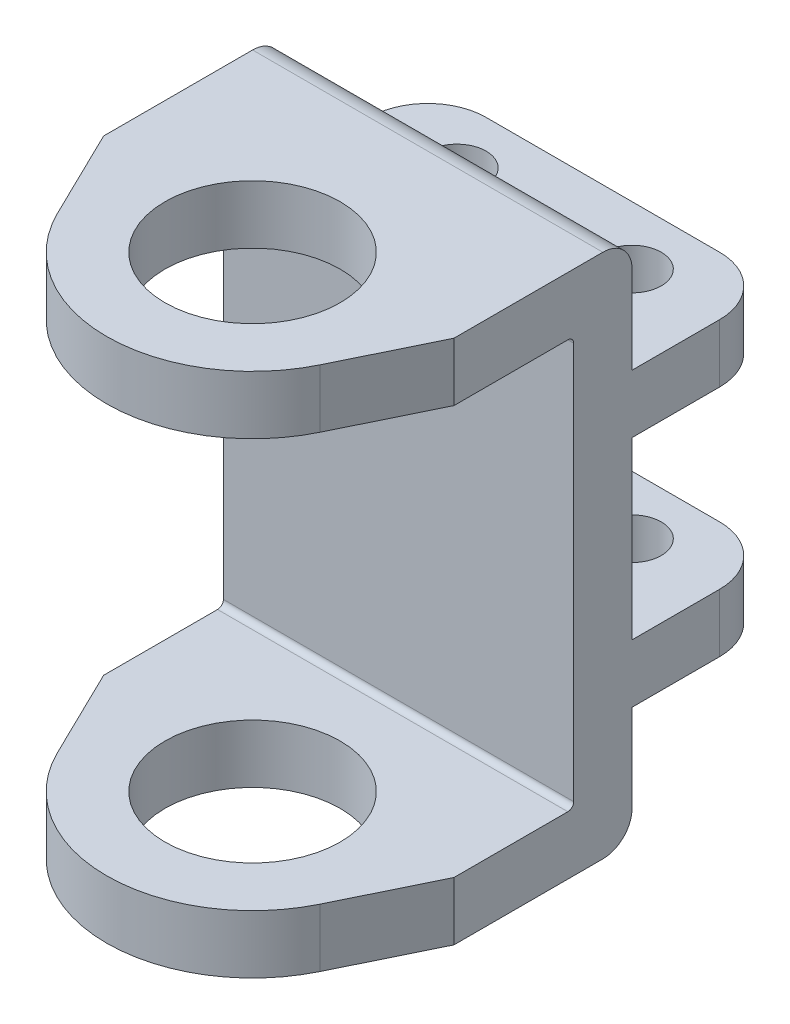
from build123d import *

# Parameters (mm, degrees)
SKETCH1_R           = 5
SKETCH1_R_2         = 15
BOSS_EXTRUDE1_DEPTH = 90
SKETCH2_W           = 25
SKETCH2_H           = 20
SKETCH2_H_2         = 30
CUT_EXTRUDE1_DEPTH  = 61
FILLET1_R           = 5


with BuildPart() as part:
    # Sketch1 → Boss-Extrude1 (new body)
    with BuildSketch(Plane(origin=(0, 0, 0), x_dir=(1, 0, 0), z_dir=(0, 1, 0))):
        with BuildLine():
            Line((30, 0), (30, 32.5))
            ThreePointArc((30, 32.5), (27.071067812, 39.571067812), (20, 42.5))
            Line((20, 42.5), (-20, 42.5))
            ThreePointArc((-20, 42.5), (-27.071067812, 39.571067812), (-30, 32.5))
            Line((-30, 32.5), (-30, 0))
            Line((-30, 0), (-30, -13.012820513))
            Line((-30, -13.012820513), (-22.471910112, -28.45505618))
            ThreePointArc((-22.471910112, -28.45505618), (0, -42.5), (22.471910112, -28.45505618))
            Line((22.471910112, -28.45505618), (30, -13.012820513))
            Line((30, -13.012820513), (30, 0))
        make_face()
        with Locations((-15, 32.5)):
            Circle(SKETCH1_R, mode=Mode.SUBTRACT)
        with Locations((15, 32.5)):
            Circle(SKETCH1_R, mode=Mode.SUBTRACT)
        with Locations((0, -17.5)):
            Circle(SKETCH1_R_2, mode=Mode.SUBTRACT)
    extrude(amount=BOSS_EXTRUDE1_DEPTH)

    # Sketch2 → Cut-Extrude1 (cut, through all)
    with BuildSketch(Plane(origin=(30, 0, 0), x_dir=(0, 0, -1), z_dir=(1, 0, 0))):
        with BuildLine():
            Line((-42.5, 80), (6.5, 80))
            ThreePointArc((6.5, 80), (7.207106781, 79.707106781), (7.5, 79))
            Line((7.5, 79), (7.5, 11))
            ThreePointArc((7.5, 11), (7.207106781, 10.292893219), (6.5, 10))
            Line((6.5, 10), (-42.5, 10))
            Line((-42.5, 10), (-42.5, 80))
        make_face()
        with Locations((30, 80)):
            Rectangle(SKETCH2_W, SKETCH2_H)
        with Locations((30, 10)):
            Rectangle(SKETCH2_W, SKETCH2_H)
        with Locations((30, 45)):
            Rectangle(SKETCH2_W, SKETCH2_H_2)
    extrude(amount=-CUT_EXTRUDE1_DEPTH, mode=Mode.SUBTRACT)

    # Fillet1
    fillet1_edges = [part.edges().sort_by_distance(p)[0] for p in [
        (0, 0, -17.5),
        (0, 90, -17.5),
    ]]
    fillet(fillet1_edges, radius=FILLET1_R)


solid = part.part
